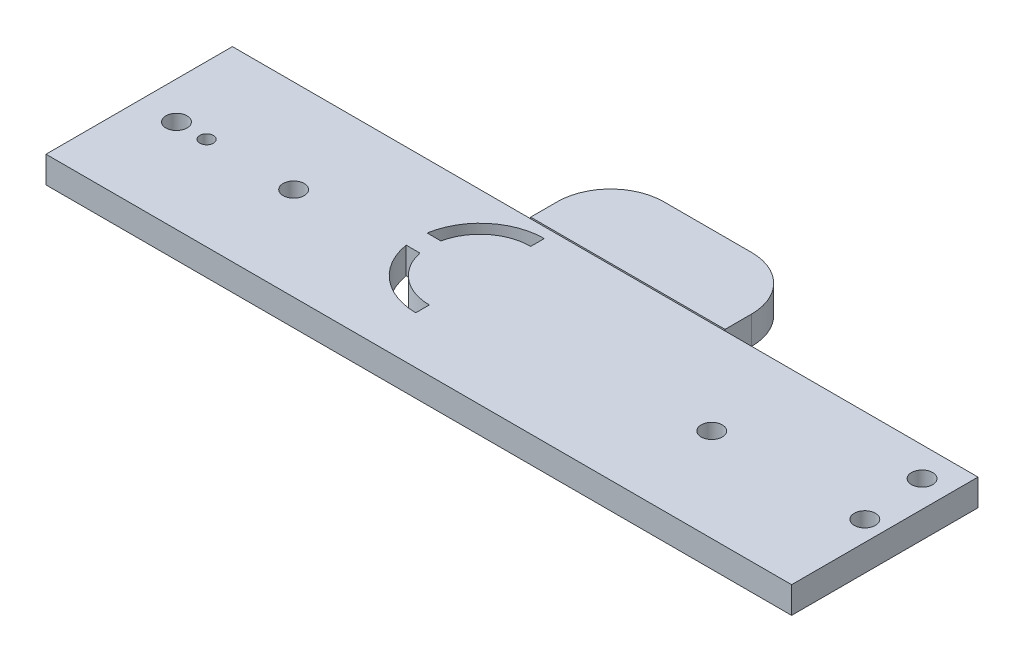
from build123d import *

# Parameters (mm, degrees)
SKETCH1_W           = 280
SKETCH1_H           = 70
SKETCH1_R           = 3.96875
SKETCH1_R_2         = 2.55
BOSS_EXTRUDE7_DEPTH = 10
SKETCH2_W           = 73
SKETCH2_H           = 10.538321467
BOSS_EXTRUDE8_DEPTH = 30
FILLET3_R           = 20
FILLET4_R           = 20
CUT_EXTRUDE1_DEPTH  = 298.489495613
CUT_EXTRUDE2_DEPTH  = 298.489495613


with BuildPart() as part:
    # Sketch1 → Boss-Extrude7 (new body)
    with BuildSketch(Plane(origin=(0, 0, 0), x_dir=(1, 0, 0), z_dir=(0, 1, 0))):
        with Locations((140, 35)):
            Rectangle(SKETCH1_W, SKETCH1_H)
        with Locations((14, 35)):
            Circle(SKETCH1_R, mode=Mode.SUBTRACT)
        with Locations((25.318924397, 35)):
            Circle(SKETCH1_R_2, mode=Mode.SUBTRACT)
        with Locations((58, 35)):
            Circle(SKETCH1_R, mode=Mode.SUBTRACT)
        with Locations((215, 35)):
            Circle(SKETCH1_R, mode=Mode.SUBTRACT)
        with Locations((272.5, 35)):
            Circle(SKETCH1_R, mode=Mode.SUBTRACT)
        with Locations((270, 59)):
            Circle(SKETCH1_R, mode=Mode.SUBTRACT)
    extrude(amount=BOSS_EXTRUDE7_DEPTH)

    # Sketch2 → Boss-Extrude8 (add)
    with BuildSketch(Plane(origin=(0, 0, -70), x_dir=(-1, 0, 0), z_dir=(0, 0, -1))):
        with Locations((-148.5, 5.269160734)):
            Rectangle(SKETCH2_W, SKETCH2_H)
    extrude(amount=BOSS_EXTRUDE8_DEPTH)

    # Fillet3
    fillet3_edges = [part.edges().sort_by_distance(p)[0] for p in [
        (185, 5.269160734, -100),
    ]]
    fillet(fillet3_edges, radius=FILLET3_R)

    # Fillet4
    fillet4_edges = [part.edges().sort_by_distance(p)[0] for p in [
        (112, 5.269160734, -100),
    ]]
    fillet(fillet4_edges, radius=FILLET4_R)

    # Sketch3 → Cut-Extrude1 (cut, through all)
    with BuildSketch(Plane(origin=(0, 10, 0), x_dir=(1, 0, 0), z_dir=(0, 1, 0))):
        with BuildLine():
            Line((121, 61.05), (121, 66.13))
            ThreePointArc((121, 66.13), (105.392513422, 60.402805839), (97.193821375, 45.939893305))
            Line((97.193821375, 45.939893305), (102.361874001, 45.939893305))
            ThreePointArc((102.361874001, 45.939893305), (109.003176826, 56.797930049), (121, 61.05))
        make_face()
    extrude(amount=-CUT_EXTRUDE1_DEPTH, mode=Mode.SUBTRACT)

    # Sketch3_3 → Cut-Extrude2 (cut, through all)
    with BuildSketch(Plane(origin=(0, 10, 0), x_dir=(1, 0, 0), z_dir=(0, 1, 0))):
        with BuildLine():
            Line((121, 17.87), (121, 22.95))
            ThreePointArc((121, 22.95), (109.003176826, 27.202069951), (102.361874001, 38.060106695))
            Line((102.361874001, 38.060106695), (97.193821375, 38.060106695))
            ThreePointArc((97.193821375, 38.060106695), (105.392513422, 23.597194161), (121, 17.87))
        make_face()
    extrude(amount=-CUT_EXTRUDE2_DEPTH, mode=Mode.SUBTRACT)


solid = part.part
